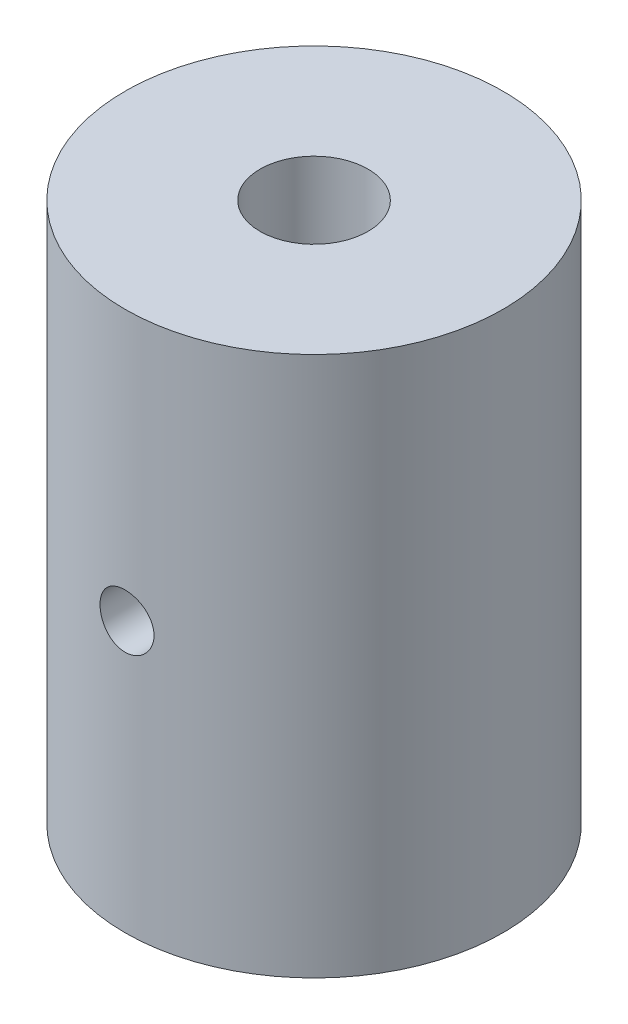
from build123d import *

# Parameters (mm, degrees)
SKETCH1_R           = 3.5
SKETCH1_R_2         = 1
BOSS_EXTRUDE1_DEPTH = 10
SKETCH2_R           = 0.5
CUT_EXTRUDE2_DEPTH  = 3.5


with BuildPart() as part:
    # Sketch1 → Boss-Extrude1 (new body)
    with BuildSketch(Plane(origin=(0, 0, 0), x_dir=(1, 0, 0), z_dir=(0, 1, 0))):
        Circle(SKETCH1_R)
        Circle(SKETCH1_R_2, mode=Mode.SUBTRACT)
    extrude(amount=BOSS_EXTRUDE1_DEPTH)

    # Sketch2 → Cut-Extrude2 (cut)
    with BuildSketch(Plane.XY.offset(3.5)):
        with Locations((0, 5)):
            Circle(SKETCH2_R)
    extrude(amount=-CUT_EXTRUDE2_DEPTH, mode=Mode.SUBTRACT)


solid = part.part
